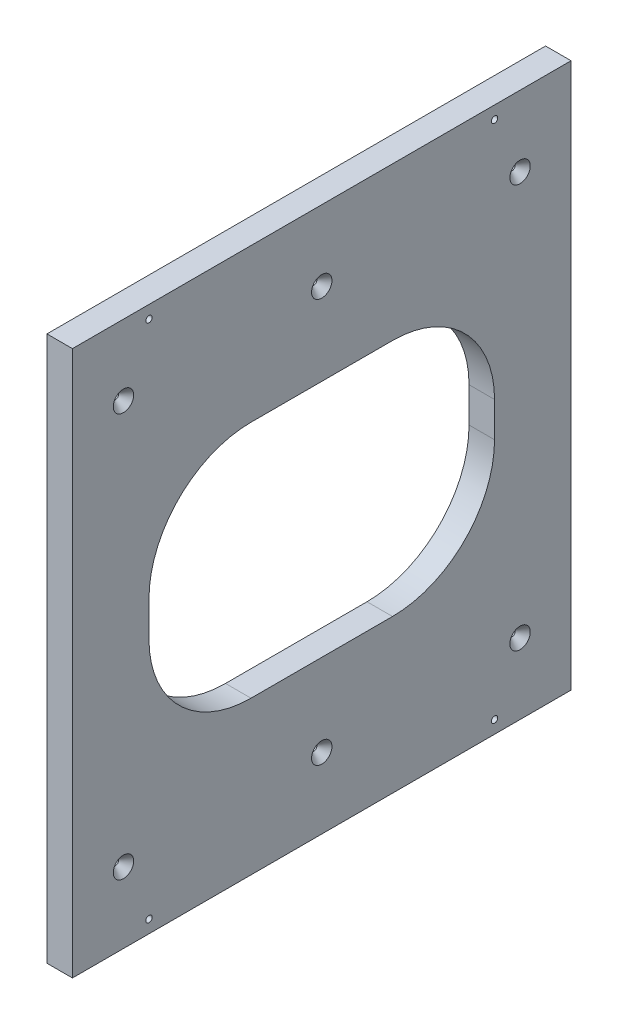
from build123d import *

# Parameters (mm, degrees)
SKETCH1_W           = 12.7
SKETCH1_H           = 271.365530146
BOSS_EXTRUDE1_DEPTH = 248.25
SKETCH2_W           = 172.05
SKETCH2_H           = 118.965530146
CUT_EXTRUDE1_DEPTH  = 13.7
FILLET1_R           = 50.8
HOLE1_D             = 3.175
HOLE1_DEPTH         = 31.75
HOLE1_CSINK_D       = 10.16
HOLE1_CSINK_ANGLE   = 82
HOLE1_TIP           = 0.953866233
HOLE2_D             = 3.175
HOLE2_DEPTH         = 31.75
HOLE2_CSINK_D       = 10.16
HOLE2_CSINK_ANGLE   = 82
HOLE2_TIP           = 0.953866233
HOLE3_D             = 3.175
HOLE3_DEPTH         = 31.75
HOLE3_CSINK_D       = 10.16
HOLE3_CSINK_ANGLE   = 82
HOLE3_TIP           = 0.953866233


with BuildPart() as part:
    # Sketch1 → Boss-Extrude1 (new body)
    with BuildSketch(Plane.XY):
        with Locations((-228.402967181, -52.841023691)):
            Rectangle(SKETCH1_W, SKETCH1_H)
    extrude(amount=BOSS_EXTRUDE1_DEPTH)

    # Sketch2 → Cut-Extrude1 (cut, through all)
    with BuildSketch(Plane.ZY.offset(234.752967181)):
        with Locations((124.125, -52.841023691)):
            Rectangle(SKETCH2_W, SKETCH2_H)
    extrude(amount=-CUT_EXTRUDE1_DEPTH, mode=Mode.SUBTRACT)

    # Fillet1
    fillet1_edges = [part.edges().sort_by_distance(p)[0] for p in [
        (-228.402967181, 6.641741382, 210.15),
        (-228.402967181, -112.323788764, 210.15),
        (-228.402967181, -112.323788764, 38.1),
        (-228.402967181, 6.641741382, 38.1),
    ]]
    fillet(fillet1_edges, radius=FILLET1_R)

    # Hole1
    with Locations(Plane(origin=(181.039434513, -52.974999997, -12.7), x_dir=(0, -1, 0), z_dir=(0, 0, -1))):
        with Locations((129.198788767, 384.042401694), (-129.466741379, 384.042401694), (-129.466741379, 304.786761906), (-110.416741379, 409.442401694), (-0.133976306, 409.442401694), (110.148788767, 409.442401694), (129.198788767, 304.786761906)):
            CounterSinkHole(HOLE1_D / 2, HOLE1_CSINK_D / 2, depth=HOLE1_DEPTH, counter_sink_angle=HOLE1_CSINK_ANGLE)
            with Locations((0, 0, -(HOLE1_DEPTH + HOLE1_TIP / 2))):  # 118° drill point
                Cone(0, HOLE1_D / 2, HOLE1_TIP, mode=Mode.SUBTRACT)

    # Hole2
    with Locations(Plane(origin=(-234.752967181, -52.974999997, -1090.512770337), x_dir=(0, -1, 0), z_dir=(-1, 0, 0))):
        with Locations((-129.466741379, 1300.662770337), (-129.466741379, 1128.612770337), (129.198788767, 1128.612770337), (129.198788767, 1300.662770337)):
            CounterSinkHole(HOLE2_D / 2, HOLE2_CSINK_D / 2, depth=HOLE2_DEPTH, counter_sink_angle=HOLE2_CSINK_ANGLE)
            with Locations((0, 0, -(HOLE2_DEPTH + HOLE2_TIP / 2))):  # 118° drill point
                Cone(0, HOLE2_D / 2, HOLE2_TIP, mode=Mode.SUBTRACT)

    # Hole3
    with Locations(Plane(origin=(-222.052967181, -52.974999997, -1090.512770337), x_dir=(0, 1, 0), z_dir=(1, 0, 0))):
        with Locations((-100.332047386, 1313.362770337), (100.599999997, 1313.362770337), (100.599999997, 1115.912770337), (100.599999997, 1214.637770337), (-100.332047386, 1214.637770337), (-100.332047386, 1115.912770337)):
            CounterSinkHole(HOLE3_D / 2, HOLE3_CSINK_D / 2, depth=HOLE3_DEPTH, counter_sink_angle=HOLE3_CSINK_ANGLE)
            with Locations((0, 0, -(HOLE3_DEPTH + HOLE3_TIP / 2))):  # 118° drill point
                Cone(0, HOLE3_D / 2, HOLE3_TIP, mode=Mode.SUBTRACT)


solid = part.part
